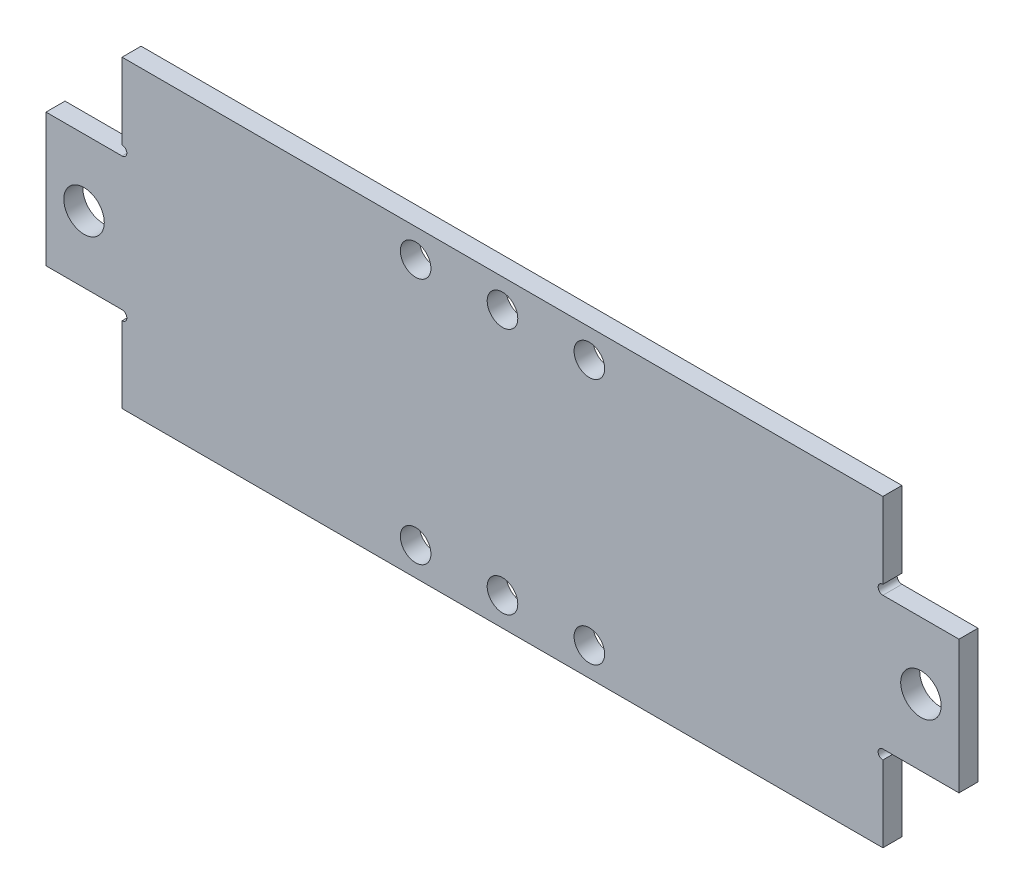
from build123d import *

# Parameters (mm, degrees)
SKETCH1_W                       = 127
SKETCH1_H                       = 50.8
BOSS_EXTRUDE1_DEPTH             = 3.175
SKETCH2_W                       = 12.7
SKETCH2_H                       = 22.225
BOSS_EXTRUDE2_DEPTH             = 3.175
SKETCH3_R                       = 0.79375
CUT_EXTRUDE1_DEPTH              = 4.175
F_1_4_CLEARANCE_HOLE1_D         = 6.7564
F_10_CLEARANCE_HOLE1_AT_2_COUNT = 2
F_10_CLEARANCE_HOLE1_AT_2_PITCH = 14.5
F_10_CLEARANCE_HOLE1_AT_3_COUNT = 2
F_10_CLEARANCE_HOLE1_AT_3_PITCH = 14.5


with BuildPart() as part:
    # Sketch1 → Boss-Extrude1 (new body)
    with BuildSketch(Plane.XY):
        with Locations((63.5, 25.4)):
            Rectangle(SKETCH1_W, SKETCH1_H)
    extrude(amount=BOSS_EXTRUDE1_DEPTH)

    # Sketch2 → Boss-Extrude2 (add)
    with BuildSketch(Plane.XY.offset(3.175)):
        with Locations((-6.35, 25.4)):
            Rectangle(SKETCH2_W, SKETCH2_H)
        with Locations((133.35, 25.4)):
            Rectangle(SKETCH2_W, SKETCH2_H)
    extrude(amount=-BOSS_EXTRUDE2_DEPTH)

    # Sketch3 → Cut-Extrude1 (cut, through all)
    with BuildSketch(Plane.XY.offset(3.175)):
        with Locations((0, 37.30625)):
            Circle(SKETCH3_R)
        with Locations((0, 13.49375)):
            Circle(SKETCH3_R)
        with Locations((127, 13.49375)):
            Circle(SKETCH3_R)
        with Locations((127, 37.30625)):
            Circle(SKETCH3_R)
    extrude(amount=-CUT_EXTRUDE1_DEPTH, mode=Mode.SUBTRACT)

    # 1/4 Clearance Hole1 (through all)
    with Locations(Plane.XY.offset(3.175)):
        with Locations((-6.35, 25.4), (133.35, 25.4)):
            Hole(F_1_4_CLEARANCE_HOLE1_D / 2)

    # Sketch6 → #10 Clearance Hole1 (revolve, cut)
    with BuildSketch(Plane(origin=(63.5, 4.7625, 3.175), x_dir=(0, -1, 0), z_dir=(1, 0, 0))):
        Polygon((0, 0), (0, 14.233816902), (2.5527, 12.7), (2.5527, 0), align=None)
    f_10_clearance_hole1 = revolve(axis=Axis((63.5, 4.7625, 9.525), (0, 0, -1)), mode=Mode.SUBTRACT)

    # #10 Clearance Hole1 at 2: #10 Clearance Hole1 ×2
    with Locations(*[(i * F_10_CLEARANCE_HOLE1_AT_2_PITCH, 0, 0) for i in range(1, F_10_CLEARANCE_HOLE1_AT_2_COUNT)]):
        add(f_10_clearance_hole1, mode=Mode.SUBTRACT)

    # #10 Clearance Hole1 at 3: #10 Clearance Hole1 ×2
    with Locations(*[(-i * F_10_CLEARANCE_HOLE1_AT_3_PITCH, 0, 0) for i in range(1, F_10_CLEARANCE_HOLE1_AT_3_COUNT)]):
        add(f_10_clearance_hole1, mode=Mode.SUBTRACT)

    # Mirror1: #10 Clearance Hole1 across plane
    add(f_10_clearance_hole1.mirror(Plane(origin=(0, 25.4, 0), x_dir=(0, 0, 1), z_dir=(0, -1, 0))), mode=Mode.SUBTRACT)

    # Mirror1 copy 1 sketch → Mirror1 copy 1 (revolve, cut)
    with BuildSketch(Plane(origin=(78, 46.0375, 3.175), x_dir=(0, 1, 0), z_dir=(1, 0, 0))):
        Polygon((0, 0), (0, -14.233816902), (2.5527, -12.7), (2.5527, 0), align=None)
    revolve(axis=Axis((78, 46.0375, 9.525), (0, 0, 1)), mode=Mode.SUBTRACT)

    # Mirror1 copy 2 sketch → Mirror1 copy 2 (revolve, cut)
    with BuildSketch(Plane(origin=(49, 46.0375, 3.175), x_dir=(0, 1, 0), z_dir=(1, 0, 0))):
        Polygon((0, 0), (0, -14.233816902), (2.5527, -12.7), (2.5527, 0), align=None)
    revolve(axis=Axis((49, 46.0375, 9.525), (0, 0, 1)), mode=Mode.SUBTRACT)


solid = part.part
